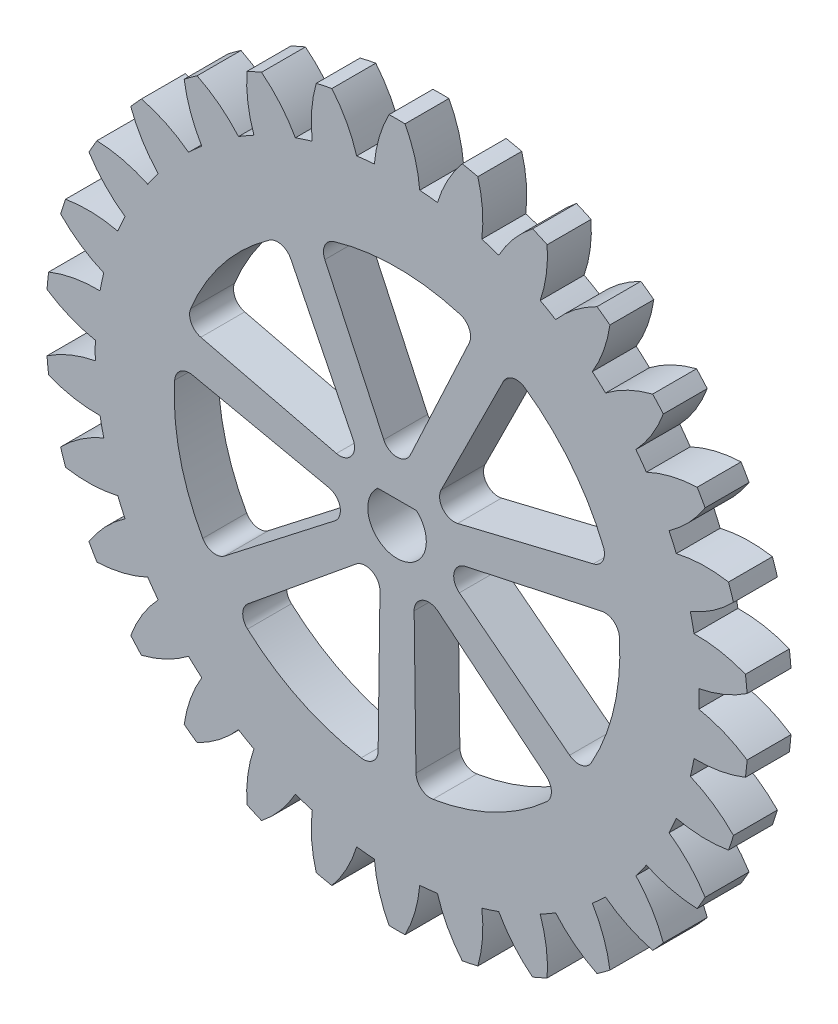
from build123d import *

# Parameters (mm, degrees)
SKETCH1_R                = 24
BOSS_EXTRUDE1_DEPTH      = 3
CUT_EXTRUDE1_DEPTH       = 4
CIRPATTERN1_COUNT        = 30
CUT_EXTRUDE3_DEPTH       = 4
FILLET6_R                = 1
CIRPATTERN3_COUNT        = 7
FILLET6_OF_CIRPATTERN3_R = 1
CUT_EXTRUDE4_DEPTH       = 10


with BuildPart() as part:
    # Sketch1 → Boss-Extrude1 (new body)
    with BuildSketch(Plane.XY):
        Circle(SKETCH1_R)
    extrude(amount=BOSS_EXTRUDE1_DEPTH)

    # Sketch2 → Cut-Extrude1 (cut, through all)
    with BuildSketch(Plane(origin=(0, 0, 0), x_dir=(-1, 0, 0), z_dir=(0, 0, -1))):
        with BuildLine():
            ThreePointArc((1.55039872, 20.566645055), (2.155899555, 20.512014092), (2.75952716, 20.439560535))
            ThreePointArc((2.75952716, 20.439560535), (3.449507996, 22.096193803), (4.45445491, 23.58299878))
            ThreePointArc((4.45445491, 23.58299878), (2.508683118, 23.868525489), (0.546066768, 23.993786927))
            ThreePointArc((0.546066768, 23.993786927), (1.219929044, 22.330531994), (1.55039872, 20.566645055))
        make_face()
    cut_extrude1 = extrude(amount=-CUT_EXTRUDE1_DEPTH, mode=Mode.SUBTRACT)

    # CirPattern1: Cut-Extrude1 ×30 about axis
    cirpattern1_axis = Axis((0, 0, 0), (0, 0, 1))
    for i in range(1, CIRPATTERN1_COUNT):
        add(cut_extrude1.rotate(cirpattern1_axis, i * 360 / CIRPATTERN1_COUNT), mode=Mode.SUBTRACT)

    # Sketch4 → Cut-Extrude3 (cut, through all)
    with BuildSketch(Plane(origin=(0, 0, 0), x_dir=(-1, 0, 0), z_dir=(0, 0, -1))):
        with BuildLine():
            Line((0, 2.628598969), (5.403618451, 14.232085842))
            ThreePointArc((5.403618451, 14.232085842), (0, 15.223382009), (-5.403618451, 14.232085842))
            Line((-5.403618451, 14.232085842), (0, 2.628598969))
        make_face()
    cut_extrude3 = extrude(amount=-CUT_EXTRUDE3_DEPTH, mode=Mode.SUBTRACT)

    # Fillet6
    fillet6_edges = [part.edges().sort_by_distance(p)[0] for p in [
        (5.403618451, 14.232085842, 1.5),
        (-5.403618451, 14.232085842, 1.5),
        (0, 2.628598969, 1.5),
    ]]
    fillet(fillet6_edges, radius=FILLET6_R)

    # CirPattern3: Cut-Extrude3 ×7 about axis
    cirpattern3_axis = Axis((0, 0, 0), (0, 0, 1))
    for i in range(1, CIRPATTERN3_COUNT):
        add(cut_extrude3.rotate(cirpattern3_axis, i * 360 / CIRPATTERN3_COUNT), mode=Mode.SUBTRACT)

    # Fillet6 of CirPattern3
    fillet6_of_cirpattern3_edges = [part.edges().sort_by_distance(p)[0] for p in [
        (-7.757991775, 13.098279407, 1.5),
        (-14.49619377, 4.648841357, 1.5),
        (-2.055121428, 1.63890465, 1.5),
        (-15.077675961, 2.101201421, 1.5),
        (-12.672839512, -8.435075489, 1.5),
        (-2.562694504, -0.584918297, 1.5),
        (-11.04356262, -10.478124091, 1.5),
        (-1.306578622, -15.167208448, 1.5),
        (-1.140506349, -2.368285837, 1.5),
        (1.306578622, -15.167208448, 1.5),
        (11.04356262, -10.478124091, 1.5),
        (1.140506349, -2.368285837, 1.5),
        (12.672839512, -8.435075489, 1.5),
        (15.077675961, 2.101201421, 1.5),
        (2.562694504, -0.584918297, 1.5),
        (14.49619377, 4.648841357, 1.5),
        (7.757991775, 13.098279407, 1.5),
        (2.055121428, 1.63890465, 1.5),
    ]]
    fillet(fillet6_of_cirpattern3_edges, radius=FILLET6_OF_CIRPATTERN3_R)

    # Sketch5 → Cut-Extrude4 (cut)
    with BuildSketch(Plane(origin=(0, 0, 0), x_dir=(-1, 0, 0), z_dir=(0, 0, -1))):
        with BuildLine():
            Line((-1.322875656, 1.5), (1.322875656, 1.5))
            ThreePointArc((1.322875656, 1.5), (0, -2), (-1.322875656, 1.5))
        make_face()
    extrude(amount=-CUT_EXTRUDE4_DEPTH, mode=Mode.SUBTRACT)


solid = part.part
